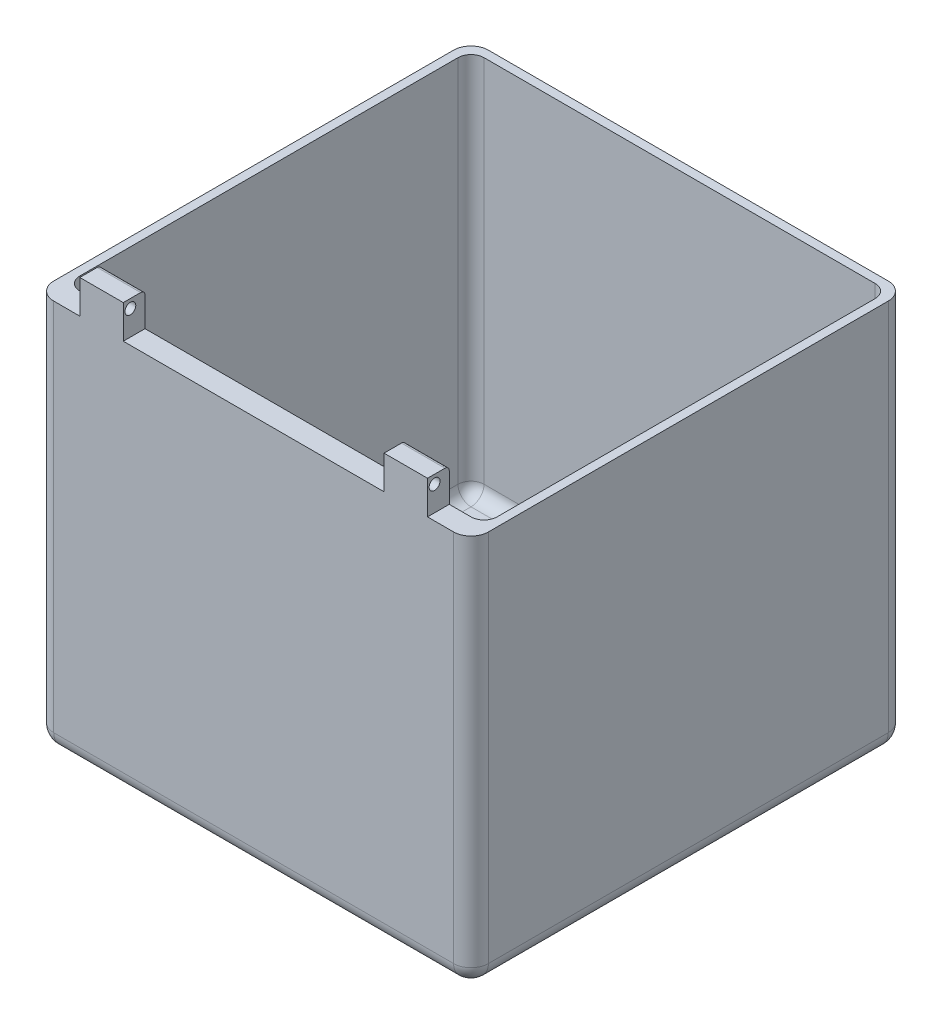
from build123d import *

# Parameters (mm, degrees)
SKETCH1_W           = 100
SKETCH1_H           = 100
BOSS_EXTRUDE1_DEPTH = 90
SKETCH2_W           = 96
SKETCH2_H           = 93
CUT_EXTRUDE1_DEPTH  = 88
CUT_EXTRUDE2_REACH  = 4
SKETCH3_R           = 3
SKETCH3_R_2         = 1.75
CHAMFER1_SIZE       = 0.8
SKETCH4_W           = 10
SKETCH4_H           = 5
BOSS_EXTRUDE2_DEPTH = 7.7
SKETCH5_R           = 1.25
CUT_EXTRUDE3_DEPTH  = 91
FILLET1_R           = 3
FILLET2_R           = 4
FILLET3_R           = 1


with BuildPart() as part:
    # Sketch1 → Boss-Extrude1 (new body)
    with BuildSketch(Plane(origin=(0, 0, 0), x_dir=(1, 0, 0), z_dir=(0, 1, 0))):
        Rectangle(SKETCH1_W, SKETCH1_H)
    extrude(amount=BOSS_EXTRUDE1_DEPTH)

    # Sketch2 → Cut-Extrude1 (cut)
    with BuildSketch(Plane(origin=(0, 90, 0), x_dir=(1, 0, 0), z_dir=(0, 1, 0))):
        with Locations((0, 1.5)):
            Rectangle(SKETCH2_W, SKETCH2_H)
    extrude(amount=-CUT_EXTRUDE1_DEPTH, mode=Mode.SUBTRACT)

    # Sketch3 → Cut-Extrude2 (cut, up to next)
    with BuildSketch(Plane(origin=(0, 2, 0), x_dir=(1, 0, 0), z_dir=(0, 1, 0)), mode=Mode.PRIVATE) as cut_extrude2_sk1:
        with Locations((-14.25, 0)):
            Circle(SKETCH3_R)
    cut_extrude2_tool1 = extrude(cut_extrude2_sk1.sketch, amount=-CUT_EXTRUDE2_REACH, mode=Mode.PRIVATE) & part.part
    add(cut_extrude2_tool1.solids().sort_by_distance((-14.25, 2, 0))[0], mode=Mode.SUBTRACT)
    # Sketch3 → Cut-Extrude2 (cut, up to next)
    with BuildSketch(Plane(origin=(0, 2, 0), x_dir=(1, 0, 0), z_dir=(0, 1, 0)), mode=Mode.PRIVATE) as cut_extrude2_sk2:
        with Locations((-30, 20)):
            Circle(SKETCH3_R_2)
    cut_extrude2_tool2 = extrude(cut_extrude2_sk2.sketch, amount=-CUT_EXTRUDE2_REACH, mode=Mode.PRIVATE) & part.part
    add(cut_extrude2_tool2.solids().sort_by_distance((-30, 2, -20))[0], mode=Mode.SUBTRACT)
    # Sketch3 → Cut-Extrude2 (cut, up to next)
    with BuildSketch(Plane(origin=(0, 2, 0), x_dir=(1, 0, 0), z_dir=(0, 1, 0)), mode=Mode.PRIVATE) as cut_extrude2_sk3:
        with Locations((-30, -20)):
            Circle(SKETCH3_R_2)
    cut_extrude2_tool3 = extrude(cut_extrude2_sk3.sketch, amount=-CUT_EXTRUDE2_REACH, mode=Mode.PRIVATE) & part.part
    add(cut_extrude2_tool3.solids().sort_by_distance((-30, 2, 20))[0], mode=Mode.SUBTRACT)
    # Sketch3 → Cut-Extrude2 (cut, up to next)
    with BuildSketch(Plane(origin=(0, 2, 0), x_dir=(1, 0, 0), z_dir=(0, 1, 0)), mode=Mode.PRIVATE) as cut_extrude2_sk4:
        with Locations((30, -20)):
            Circle(SKETCH3_R_2)
    cut_extrude2_tool4 = extrude(cut_extrude2_sk4.sketch, amount=-CUT_EXTRUDE2_REACH, mode=Mode.PRIVATE) & part.part
    add(cut_extrude2_tool4.solids().sort_by_distance((30, 2, 20))[0], mode=Mode.SUBTRACT)
    # Sketch3 → Cut-Extrude2 (cut, up to next)
    with BuildSketch(Plane(origin=(0, 2, 0), x_dir=(1, 0, 0), z_dir=(0, 1, 0)), mode=Mode.PRIVATE) as cut_extrude2_sk5:
        with Locations((30, 20)):
            Circle(SKETCH3_R_2)
    cut_extrude2_tool5 = extrude(cut_extrude2_sk5.sketch, amount=-CUT_EXTRUDE2_REACH, mode=Mode.PRIVATE) & part.part
    add(cut_extrude2_tool5.solids().sort_by_distance((30, 2, -20))[0], mode=Mode.SUBTRACT)
    # Sketch3 → Cut-Extrude2 (cut, up to next)
    with BuildSketch(Plane(origin=(0, 2, 0), x_dir=(1, 0, 0), z_dir=(0, 1, 0)), mode=Mode.PRIVATE) as cut_extrude2_sk6:
        with BuildLine():
            Line((0, 1.25), (22, 1.25))
            ThreePointArc((22, 1.25), (23.25, 0), (22, -1.25))
            Line((22, -1.25), (0, -1.25))
            ThreePointArc((0, -1.25), (-1.25, 0), (0, 1.25))
        make_face()
    cut_extrude2_tool6 = extrude(cut_extrude2_sk6.sketch, amount=-CUT_EXTRUDE2_REACH, mode=Mode.PRIVATE) & part.part
    add(cut_extrude2_tool6.solids().sort_by_distance((11, 2, 0))[0], mode=Mode.SUBTRACT)

    # Chamfer1
    chamfer1_edges = [part.edges().sort_by_distance(p)[0] for p in [
        (-31.75, 0, -20),
        (-31.75, 0, 20),
        (28.25, 0, 20),
        (28.25, 0, -20),
    ]]
    chamfer(chamfer1_edges, length=CHAMFER1_SIZE)

    # Sketch4 → Boss-Extrude2 (add)
    with BuildSketch(Plane(origin=(0, 90, 0), x_dir=(1, 0, 0), z_dir=(0, 1, 0))):
        with Locations((-35, -47.5)):
            Rectangle(SKETCH4_W, SKETCH4_H)
        with Locations((35, -47.5)):
            Rectangle(SKETCH4_W, SKETCH4_H)
    extrude(amount=BOSS_EXTRUDE2_DEPTH)

    # Sketch5 → Cut-Extrude3 (cut, through all)
    with BuildSketch(Plane.ZY.offset(40)):
        with Locations((48.375, 95.7)):
            Circle(SKETCH5_R)
    extrude(amount=-CUT_EXTRUDE3_DEPTH, mode=Mode.SUBTRACT)

    # Fillet1
    fillet1_edges = [part.edges().sort_by_distance(p)[0] for p in [
        (-48, 2, -1.5),
        (-48, 46, 45),
        (0, 2, 45),
        (48, 46, 45),
        (48, 2, -1.5),
        (48, 46, -48),
        (0, 2, -48),
        (-48, 46, -48),
    ]]
    fillet(fillet1_edges, radius=FILLET1_R)

    # Fillet2
    fillet2_edges = [part.edges().sort_by_distance(p)[0] for p in [
        (0, 0, 50),
        (-50, 0, 0),
        (0, 0, -50),
        (50, 0, 0),
        (50, 45, 50),
        (-50, 45, 50),
        (-50, 45, -50),
        (50, 45, -50),
    ]]
    fillet(fillet2_edges, radius=FILLET2_R)

    # Fillet3
    fillet3_edges = [part.edges().sort_by_distance(p)[0] for p in [
        (-35, 97.7, 45),
        (35, 97.7, 45),
    ]]
    fillet(fillet3_edges, radius=FILLET3_R)


solid = part.part
